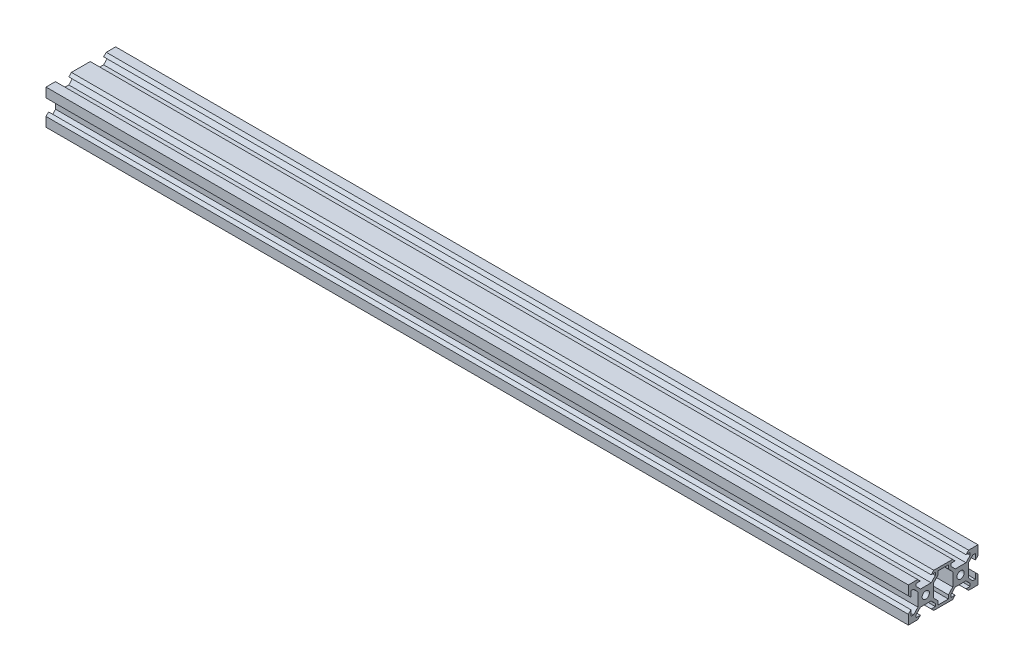
from build123d import *

# Parameters (mm, degrees)
SKETCH1_R           = 2.1
BOSS_EXTRUDE2_DEPTH = 495.3


with BuildPart() as part:
    # Sketch1 → Boss-Extrude2 (new body)
    with BuildSketch(Plane(origin=(0, 0, 0), x_dir=(0, 0, -1), z_dir=(1, 0, 0))):
        Polygon((-20, -4.6), (-20, -10), (-14.6, -10), (-13.1, -8.5), (-15.5, -8.5), (-15.5, -7), (-13.1, -4.5), (-6.9, -4.5), (-4.5, -7), (-4.5, -8.5), (-6.9, -8.5), (-5.4, -10), (0, -10), (0, -8.5), (-3, -8.5), (-3, -6.396534569), (-5.5, -3.792367902), (-5.5, 3.792367902), (-3, 6.396534569), (-3, 8.5), (0, 8.5), (0, 10), (-5.4, 10), (-6.9, 8.5), (-4.5, 8.5), (-4.5, 7), (-6.9, 4.5), (-13.1, 4.5), (-15.5, 7), (-15.5, 8.5), (-13.1, 8.5), (-14.6, 10), (-20, 10), (-20, 4.6), (-18.5, 3.1), (-18.5, 6.396534569), (-17, 6.396534569), (-14.5, 3.792367902), (-14.5, -3.792367902), (-17, -6.396534569), (-18.5, -6.396534569), (-18.5, -3.1), align=None)
        with Locations((-10, 0)):
            Circle(SKETCH1_R, mode=Mode.SUBTRACT)
        Polygon((0, -8.5), (0, -10), (5.4, -10), (6.9, -8.5), (4.5, -8.5), (4.5, -7), (6.9, -4.5), (13.1, -4.5), (15.5, -7), (15.5, -8.5), (13.1, -8.5), (14.6, -10), (20, -10), (20, -4.6), (18.5, -3.1), (18.5, -6.396534569), (17, -6.396534569), (14.5, -3.792367902), (14.5, 3.792367902), (17, 6.396534569), (18.5, 6.396534569), (18.5, 3.1), (20, 4.6), (20, 10), (14.6, 10), (13.1, 8.5), (15.5, 8.5), (15.5, 7), (13.1, 4.5), (6.9, 4.5), (4.5, 7), (4.5, 8.5), (6.9, 8.5), (5.4, 10), (0, 10), (0, 8.5), (3, 8.5), (3, 6.396534569), (5.5, 3.792367902), (5.5, -3.792367902), (3, -6.396534569), (3, -8.5), align=None)
        with Locations((10, 0)):
            Circle(SKETCH1_R, mode=Mode.SUBTRACT)
    extrude(amount=BOSS_EXTRUDE2_DEPTH)


solid = part.part
